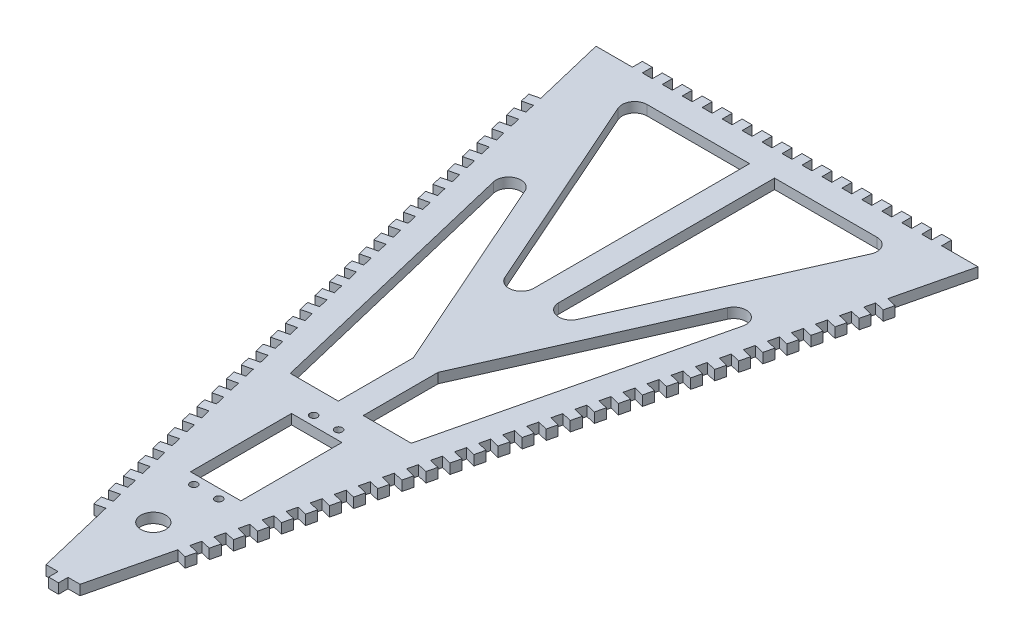
from build123d import *

# Parameters (mm, degrees)
BOSS_EXTRUDE1_DEPTH = 4
BOSS_EXTRUDE2_DEPTH = 4
SKETCH3_W           = 4
SKETCH3_H           = 4
BOSS_EXTRUDE3_DEPTH = 4
CUT_EXTRUDE1_DEPTH  = 4
SKETCH5_R           = 5
CUT_EXTRUDE2_DEPTH  = 10
SKETCH6_R           = 1.5
SKETCH6_W           = 20.2
SKETCH6_H           = 40.5
CUT_EXTRUDE3_DEPTH  = 4


with BuildPart() as part:
    # Sketch1 → Boss-Extrude1 (new body)
    with BuildSketch(Plane(origin=(0, 0, 0), x_dir=(1, 0, 0), z_dir=(0, 1, 0))):
        Polygon((-76.56, 0), (76.56, 0), (6.83, -290.230954931), (-6.83, -290.230954931), align=None)
    extrude(amount=-BOSS_EXTRUDE1_DEPTH)

    # Sketch2 → Boss-Extrude2 (add)
    with BuildSketch(Plane(origin=(0, 0, 0), x_dir=(1, 0, 0), z_dir=(0, 1, 0))):
        Polygon((-69.551725016, -29.169917411), (-73.441047337, -30.104354075), (-72.506610673, -33.993676397), (-68.617288351, -33.059239732), align=None)
        Polygon((-67.682851687, -36.948562054), (-71.572174008, -37.882998718), (-70.637737344, -41.77232104), (-66.748415022, -40.837884375), align=None)
        Polygon((-65.813978358, -44.727206696), (-69.703300679, -45.661643361), (-68.768864015, -49.550965682), (-64.879541693, -48.616529018), align=None)
        Polygon((-63.945105029, -52.505851339), (-67.83442735, -53.440288004), (-66.899990686, -57.329610325), (-63.010668364, -56.395173661), align=None)
        Polygon((-62.0762317, -60.284495982), (-65.965554021, -61.218932647), (-65.031117356, -65.108254968), (-61.141795035, -64.173818304), align=None)
        Polygon((-60.20735837, -68.063140625), (-64.096680692, -68.99757729), (-63.162244027, -72.886899611), (-59.272921706, -71.952462946), align=None)
        Polygon((-58.338485041, -75.841785268), (-62.227807363, -76.776221932), (-61.293370698, -80.665544254), (-57.404048377, -79.731107589), align=None)
        Polygon((-56.469611712, -83.620429911), (-60.358934034, -84.554866575), (-59.424497369, -88.444188897), (-55.535175048, -87.509752232), align=None)
        Polygon((-54.600738383, -91.399074554), (-58.490060705, -92.333511218), (-57.55562404, -96.22283354), (-53.666301719, -95.288396875), align=None)
        Polygon((-52.731865054, -99.177719196), (-56.621187376, -100.112155861), (-55.686750711, -104.001478182), (-51.79742839, -103.067041518), align=None)
        Polygon((-50.862991725, -106.956363839), (-54.752314046, -107.890800504), (-53.817877382, -111.780122825), (-49.92855506, -110.845686161), align=None)
        Polygon((-48.994118396, -114.735008482), (-52.883440717, -115.669445147), (-51.949004053, -119.558767468), (-48.059681731, -118.624330804), align=None)
        Polygon((-47.125245067, -122.513653125), (-51.014567388, -123.44808979), (-50.080130724, -127.337412111), (-46.190808402, -126.402975446), align=None)
        Polygon((-45.256371738, -130.292297768), (-49.145694059, -131.226734432), (-48.211257395, -135.116056754), (-44.321935073, -134.181620089), align=None)
        Polygon((-43.387498409, -138.070942411), (-47.27682073, -139.005379075), (-46.342384066, -142.894701397), (-42.453061744, -141.960264732), align=None)
        Polygon((-41.51862508, -145.849587054), (-45.407947401, -146.784023718), (-44.473510736, -150.67334604), (-40.584188415, -149.738909375), align=None)
        Polygon((-39.64975175, -153.628231696), (-43.539074072, -154.562668361), (-42.604637407, -158.451990682), (-38.715315086, -157.517554018), align=None)
        Polygon((-37.780878421, -161.406876339), (-41.670200743, -162.341313004), (-40.735764078, -166.230635325), (-36.846441757, -165.296198661), align=None)
        Polygon((-35.912005092, -169.185520982), (-39.801327414, -170.119957647), (-38.866890749, -174.009279968), (-34.977568428, -173.074843304), align=None)
        Polygon((-34.043131763, -176.964165625), (-37.932454085, -177.898602289), (-36.99801742, -181.787924611), (-33.108695099, -180.853487946), align=None)
        Polygon((-32.174258434, -184.742810268), (-36.063580756, -185.677246932), (-35.129144091, -189.566569254), (-31.23982177, -188.632132589), align=None)
        Polygon((-30.305385105, -192.521454911), (-34.194707426, -193.455891575), (-33.260270762, -197.345213897), (-29.37094844, -196.410777232), align=None)
        Polygon((-28.436511776, -200.300099554), (-32.325834097, -201.234536218), (-31.391397433, -205.123858539), (-27.502075111, -204.189421875), align=None)
        Polygon((-26.567638447, -208.078744196), (-30.456960768, -209.013180861), (-29.522524104, -212.902503182), (-25.633201782, -211.968066518), align=None)
        Polygon((-24.698765118, -215.857388839), (-28.588087439, -216.791825504), (-27.653650775, -220.681147825), (-23.764328453, -219.746711161), align=None)
        Polygon((-22.829891789, -223.636033482), (-26.71921411, -224.570470147), (-25.784777446, -228.459792468), (-21.895455124, -227.525355804), align=None)
        Polygon((-20.96101846, -231.414678125), (-24.850340781, -232.349114789), (-23.915904116, -236.238437111), (-20.026581795, -235.304000446), align=None)
        Polygon((-19.09214513, -239.193322768), (-22.981467452, -240.127759432), (-22.047030787, -244.017081754), (-18.157708466, -243.082645089), align=None)
        Polygon((-17.223271801, -246.971967411), (-21.112594123, -247.906404075), (-20.178157458, -251.795726397), (-16.288835137, -250.861289732), align=None)
        Polygon((-15.354398472, -254.750612053), (-19.243720794, -255.685048718), (-18.309284129, -259.574371039), (-14.419961808, -258.639934375), align=None)
        Polygon((14.419961808, -258.639934375), (15.354398472, -254.750612053), (19.243720794, -255.685048718), (18.309284129, -259.574371039), align=None)
        Polygon((16.288835137, -250.861289732), (17.223271801, -246.971967411), (21.112594123, -247.906404075), (20.178157458, -251.795726397), align=None)
        Polygon((18.157708466, -243.082645089), (19.09214513, -239.193322768), (22.981467452, -240.127759432), (22.047030787, -244.017081754), align=None)
        Polygon((20.026581795, -235.304000446), (20.96101846, -231.414678125), (24.850340781, -232.349114789), (23.915904116, -236.238437111), align=None)
        Polygon((21.895455124, -227.525355804), (22.829891789, -223.636033482), (26.71921411, -224.570470147), (25.784777446, -228.459792468), align=None)
        Polygon((23.764328453, -219.746711161), (24.698765118, -215.857388839), (28.588087439, -216.791825504), (27.653650775, -220.681147825), align=None)
        Polygon((25.633201782, -211.968066518), (26.567638447, -208.078744196), (30.456960768, -209.013180861), (29.522524104, -212.902503182), align=None)
        Polygon((27.502075111, -204.189421875), (28.436511776, -200.300099554), (32.325834097, -201.234536218), (31.391397433, -205.123858539), align=None)
        Polygon((29.37094844, -196.410777232), (30.305385105, -192.521454911), (34.194707426, -193.455891575), (33.260270762, -197.345213897), align=None)
        Polygon((31.23982177, -188.632132589), (32.174258434, -184.742810268), (36.063580756, -185.677246932), (35.129144091, -189.566569254), align=None)
        Polygon((33.108695099, -180.853487946), (34.043131763, -176.964165625), (37.932454085, -177.898602289), (36.99801742, -181.787924611), align=None)
        Polygon((34.977568428, -173.074843304), (35.912005092, -169.185520982), (39.801327414, -170.119957647), (38.866890749, -174.009279968), align=None)
        Polygon((36.846441757, -165.296198661), (37.780878421, -161.406876339), (41.670200743, -162.341313004), (40.735764078, -166.230635325), align=None)
        Polygon((38.715315086, -157.517554018), (39.64975175, -153.628231696), (43.539074072, -154.562668361), (42.604637407, -158.451990682), align=None)
        Polygon((40.584188415, -149.738909375), (41.51862508, -145.849587054), (45.407947401, -146.784023718), (44.473510736, -150.67334604), align=None)
        Polygon((42.453061744, -141.960264732), (43.387498409, -138.070942411), (47.27682073, -139.005379075), (46.342384066, -142.894701397), align=None)
        Polygon((44.321935073, -134.181620089), (45.256371738, -130.292297768), (49.145694059, -131.226734432), (48.211257395, -135.116056754), align=None)
        Polygon((46.190808402, -126.402975446), (47.125245067, -122.513653125), (51.014567388, -123.44808979), (50.080130724, -127.337412111), align=None)
        Polygon((48.059681731, -118.624330804), (48.994118396, -114.735008482), (52.883440717, -115.669445147), (51.949004053, -119.558767468), align=None)
        Polygon((49.92855506, -110.845686161), (50.862991725, -106.956363839), (54.752314046, -107.890800504), (53.817877382, -111.780122825), align=None)
        Polygon((51.79742839, -103.067041518), (52.731865054, -99.177719196), (56.621187376, -100.112155861), (55.686750711, -104.001478182), align=None)
        Polygon((53.666301719, -95.288396875), (54.600738383, -91.399074554), (58.490060705, -92.333511218), (57.55562404, -96.22283354), align=None)
        Polygon((55.535175048, -87.509752232), (56.469611712, -83.620429911), (60.358934034, -84.554866575), (59.424497369, -88.444188897), align=None)
        Polygon((57.404048377, -79.731107589), (58.338485041, -75.841785268), (62.227807363, -76.776221932), (61.293370698, -80.665544254), align=None)
        Polygon((59.272921706, -71.952462946), (60.20735837, -68.063140625), (64.096680692, -68.99757729), (63.162244027, -72.886899611), align=None)
        Polygon((61.141795035, -64.173818304), (62.0762317, -60.284495982), (65.965554021, -61.218932647), (65.031117356, -65.108254968), align=None)
        Polygon((63.010668364, -56.395173661), (63.945105029, -52.505851339), (67.83442735, -53.440288004), (66.899990686, -57.329610325), align=None)
        Polygon((64.879541693, -48.616529018), (65.813978358, -44.727206696), (69.703300679, -45.661643361), (68.768864015, -49.550965682), align=None)
        Polygon((66.748415022, -40.837884375), (67.682851687, -36.948562054), (71.572174008, -37.882998718), (70.637737344, -41.77232104), align=None)
        Polygon((68.617288351, -33.059239732), (69.551725016, -29.169917411), (73.441047337, -30.104354075), (72.506610673, -33.993676397), align=None)
    extrude(amount=-BOSS_EXTRUDE2_DEPTH)

    # Sketch3 → Boss-Extrude3 (add)
    with BuildSketch(Plane(origin=(0, 0, 0), x_dir=(1, 0, 0), z_dir=(0, 1, 0))):
        with Locations((-4, 2)):
            Rectangle(SKETCH3_W, SKETCH3_H)
        with Locations((-12, 2)):
            Rectangle(SKETCH3_W, SKETCH3_H)
        with Locations((-20, 2)):
            Rectangle(SKETCH3_W, SKETCH3_H)
        with Locations((-28, 2)):
            Rectangle(SKETCH3_W, SKETCH3_H)
        with Locations((-36, 2)):
            Rectangle(SKETCH3_W, SKETCH3_H)
        with Locations((-44, 2)):
            Rectangle(SKETCH3_W, SKETCH3_H)
        with Locations((-52, 2)):
            Rectangle(SKETCH3_W, SKETCH3_H)
        with Locations((-60, 2)):
            Rectangle(SKETCH3_W, SKETCH3_H)
        with Locations((60, 2)):
            Rectangle(SKETCH3_W, SKETCH3_H)
        with Locations((52, 2)):
            Rectangle(SKETCH3_W, SKETCH3_H)
        with Locations((44, 2)):
            Rectangle(SKETCH3_W, SKETCH3_H)
        with Locations((36, 2)):
            Rectangle(SKETCH3_W, SKETCH3_H)
        with Locations((28, 2)):
            Rectangle(SKETCH3_W, SKETCH3_H)
        with Locations((20, 2)):
            Rectangle(SKETCH3_W, SKETCH3_H)
        with Locations((12, 2)):
            Rectangle(SKETCH3_W, SKETCH3_H)
        with Locations((4, 2)):
            Rectangle(SKETCH3_W, SKETCH3_H)
        with Locations((0, -292.030285488)):
            Rectangle(SKETCH3_W, SKETCH3_H)
    extrude(amount=-BOSS_EXTRUDE3_DEPTH)

    # Sketch4 → Cut-Extrude1 (cut)
    with BuildSketch(Plane(origin=(0, 0, 0), x_dir=(1, 0, 0), z_dir=(0, 1, 0))):
        with BuildLine():
            Line((-46.075428014, -10), (-5, -10))
            Line((-5, -10), (-5, -96.513661003))
            ThreePointArc((-5, -96.513661003), (-8.965875271, -101.405550827), (-14.572234418, -98.537190698))
            Line((-14.572234418, -98.537190698), (-50.647662432, -17.023529695))
            ThreePointArc((-50.647662432, -17.023529695), (-50.26575309, -12.272148142), (-46.075428014, -10))
        make_face()
        with BuildLine():
            Line((-40.585962549, -64.467582892), (-5, -144.87527997))
            Line((-5, -144.87527997), (-5, -174.87527997))
            Line((-5, -174.87527997), (-24.260433002, -174.87527997))
            Line((-24.260433002, -174.87527997), (-50.019849869, -67.659158418))
            ThreePointArc((-50.019849869, -67.659158418), (-46.760532559, -61.754814386), (-40.585962549, -64.467582892))
        make_face()
        with BuildLine():
            Line((24.260433002, -174.87527997), (50.019849869, -67.659158418))
            ThreePointArc((50.019849869, -67.659158418), (46.760532559, -61.754814386), (40.585962549, -64.467582892))
            Line((40.585962549, -64.467582892), (5, -144.87527997))
            Line((5, -144.87527997), (5, -174.87527997))
            Line((5, -174.87527997), (24.260433002, -174.87527997))
        make_face()
        with BuildLine():
            Line((14.572234418, -98.537190698), (50.647662432, -17.023529695))
            ThreePointArc((50.647662432, -17.023529695), (50.26575309, -12.272148142), (46.075428014, -10))
            Line((46.075428014, -10), (5, -10))
            Line((5, -10), (5, -96.513661003))
            ThreePointArc((5, -96.513661003), (8.965875271, -101.405550827), (14.572234418, -98.537190698))
        make_face()
    extrude(amount=-CUT_EXTRUDE1_DEPTH, mode=Mode.SUBTRACT)

    # Sketch5 → Cut-Extrude2 (cut)
    with BuildSketch(Plane(origin=(0, 0, 0), x_dir=(1, 0, 0), z_dir=(0, 1, 0))):
        with Locations((0, -254.030285488)):
            Circle(SKETCH5_R)
    extrude(amount=-CUT_EXTRUDE2_DEPTH, mode=Mode.SUBTRACT)

    # Sketch6 → Cut-Extrude3 (cut)
    with BuildSketch(Plane(origin=(0, 0, 0), x_dir=(1, 0, 0), z_dir=(0, 1, 0))):
        with Locations((-5, -184.780285488)):
            Circle(SKETCH6_R)
        with Locations((5, -184.780285488)):
            Circle(SKETCH6_R)
        with Locations((5, -232.780285488)):
            Circle(SKETCH6_R)
        with Locations((-5, -232.780285488)):
            Circle(SKETCH6_R)
        with Locations((0, -208.780285488)):
            Rectangle(SKETCH6_W, SKETCH6_H)
    extrude(amount=-CUT_EXTRUDE3_DEPTH, mode=Mode.SUBTRACT)


solid = part.part
